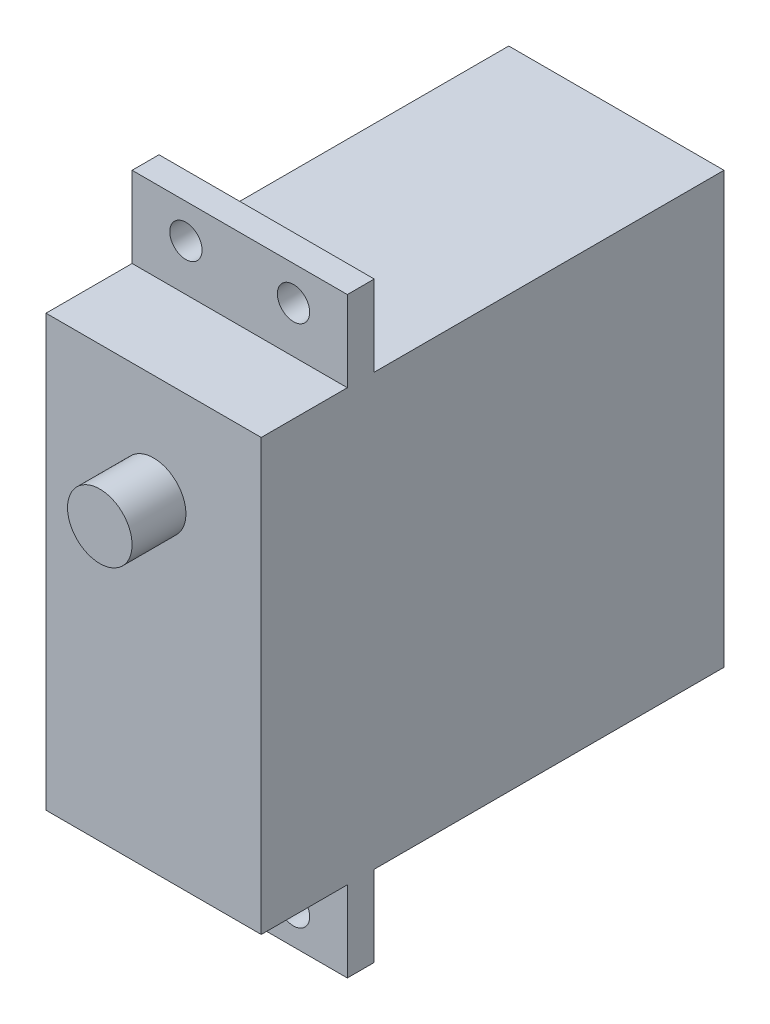
from build123d import *

# Parameters (mm, degrees)
SKETCH_1_W          = 20
SKETCH_1_H          = 40
EXTRUDE_1_DEPTH     = 32.5
SKETCH_2_W          = 20
SKETCH_2_H          = 55
EXTRUDE_2_DEPTH     = 2.5
SKETCH_3_W          = 20
SKETCH_3_H          = 40
EXTRUDE_3_DEPTH     = 8
SKETCH_4_R          = 3
EXTRUDE_4_DEPTH     = 5
SKETCH_5_R          = 1.5
CUT_EXTRUDE_1_DEPTH = 36


with BuildPart() as part:
    # 草图1 → 凸台-拉伸1 (new body)
    with BuildSketch(Plane.XY):
        Rectangle(SKETCH_1_W, SKETCH_1_H)
    extrude(amount=EXTRUDE_1_DEPTH)

    # 草图2 → 凸台-拉伸2 (add)
    with BuildSketch(Plane.XY.offset(32.5)):
        Rectangle(SKETCH_2_W, SKETCH_2_H)
    extrude(amount=EXTRUDE_2_DEPTH)

    # 草图3 → 凸台-拉伸3 (add)
    with BuildSketch(Plane.XY.offset(35)):
        Rectangle(SKETCH_3_W, SKETCH_3_H)
    extrude(amount=EXTRUDE_3_DEPTH)

    # 草图4 → 凸台-拉伸4 (add)
    with BuildSketch(Plane.XY.offset(43)):
        with Locations((0, 10.35)):
            Circle(SKETCH_4_R)
    extrude(amount=EXTRUDE_4_DEPTH)

    # 草图5 → 切除-拉伸1 (cut, through all)
    with BuildSketch(Plane.XY.offset(35)):
        with Locations((-5, 24.315)):
            Circle(SKETCH_5_R)
        with Locations((5, 24.315)):
            Circle(SKETCH_5_R)
        with Locations((-5, -24.315)):
            Circle(SKETCH_5_R)
        with Locations((5, -24.315)):
            Circle(SKETCH_5_R)
    extrude(amount=-CUT_EXTRUDE_1_DEPTH, mode=Mode.SUBTRACT)


solid = part.part
